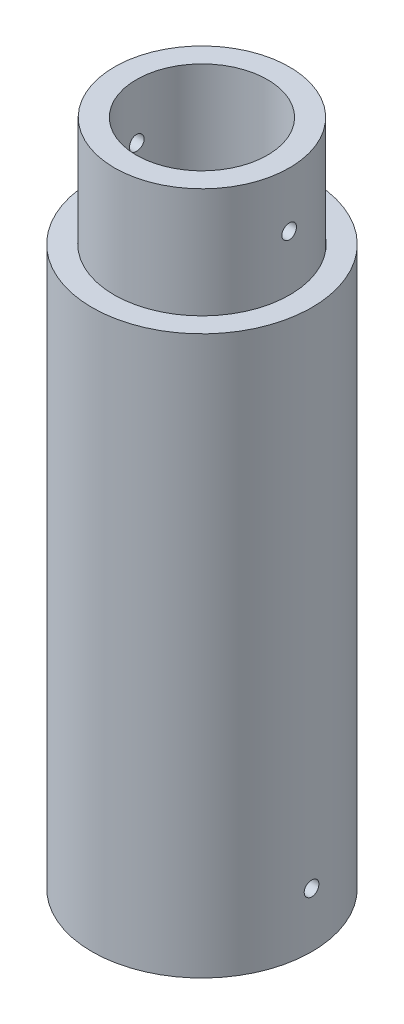
from build123d import *

# Parameters (mm, degrees)
SKETCH1_R                = 15
SKETCH1_R_2              = 12
BOSS_EXTRUDE1_DEPTH      = 76.2
SKETCH2_R                = 11.95
SKETCH2_R_2              = 8.95
BOSS_EXTRUDE2_DEPTH      = 15
BOSS_EXTRUDE2_DEPTH_BACK = 3
SKETCH3_R                = 1
CUT_EXTRUDE1_DEPTH       = 16
CUT_EXTRUDE1_DEPTH_BACK  = 16


with BuildPart() as part:
    # Sketch1 → Boss-Extrude1 (new body)
    with BuildSketch(Plane(origin=(0, 0, 0), x_dir=(1, 0, 0), z_dir=(0, 1, 0))):
        Circle(SKETCH1_R)
        Circle(SKETCH1_R_2, mode=Mode.SUBTRACT)
    extrude(amount=BOSS_EXTRUDE1_DEPTH)


with BuildPart() as body_2:
    # Sketch2 → Boss-Extrude2 (new body, two sides)
    with BuildSketch(Plane(origin=(0, 76.2, 0), x_dir=(1, 0, 0), z_dir=(0, 1, 0))) as boss_extrude2_sk:
        Circle(SKETCH2_R)
        Circle(SKETCH2_R_2, mode=Mode.SUBTRACT)
    extrude(amount=BOSS_EXTRUDE2_DEPTH)
    extrude(boss_extrude2_sk.sketch, amount=-BOSS_EXTRUDE2_DEPTH_BACK)


with BuildPart() as cut_extrude1_tool:
    # Sketch3 → Cut-Extrude1 (new body, two sides)
    with BuildSketch(Plane(origin=(0, 0, 0), x_dir=(0, 0, -1), z_dir=(1, 0, 0))) as cut_extrude1_sk:
        with Locations((0, 83.7)):
            Circle(SKETCH3_R)
        with Locations((0, 7.5)):
            Circle(SKETCH3_R)
    extrude(amount=CUT_EXTRUDE1_DEPTH)
    extrude(cut_extrude1_sk.sketch, amount=-CUT_EXTRUDE1_DEPTH_BACK)


with BuildPart() as part_1:
    add(part.part)

    # Cut-Extrude1: cut by cut_extrude1_tool
    add(cut_extrude1_tool.part, mode=Mode.SUBTRACT)


with BuildPart() as body_2_1:
    add(body_2.part)

    # Cut-Extrude1: cut by cut_extrude1_tool
    add(cut_extrude1_tool.part, mode=Mode.SUBTRACT)


solid = Compound([part_1.part, body_2_1.part])
